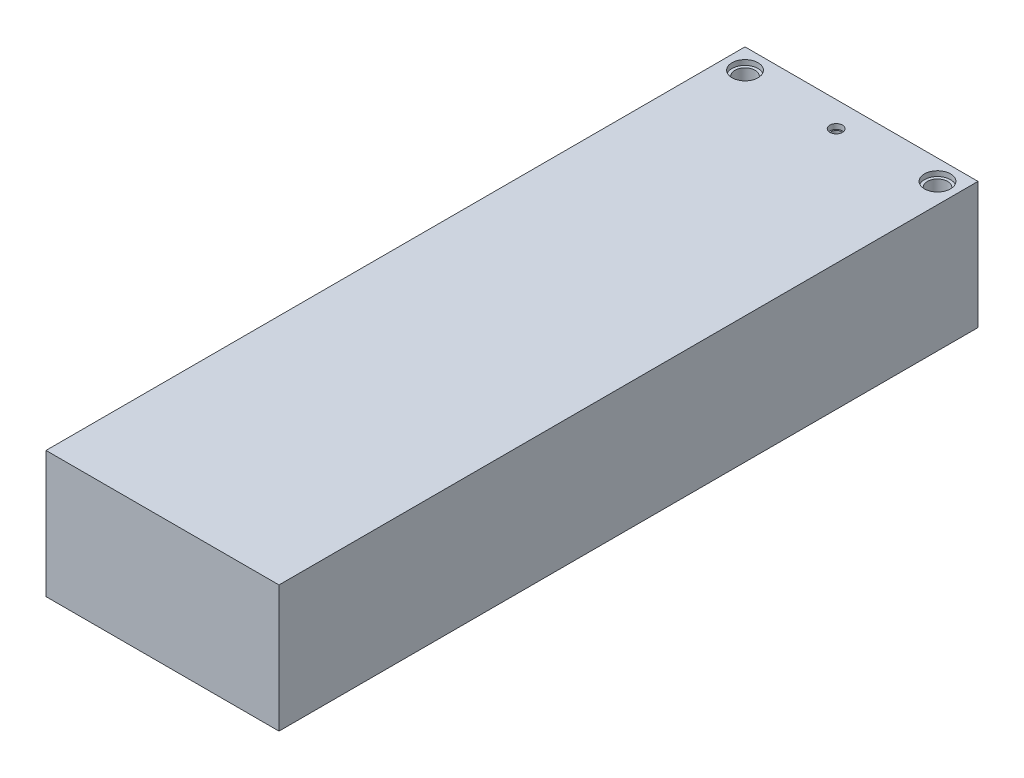
from build123d import *

# Parameters (mm, degrees)
SKETCH2_W           = 46
SKETCH2_H           = 25
BOSS_EXTRUDE1_DEPTH = 138
SKETCH3_R           = 2.575
SKETCH3_R_2         = 1.25
CUT_EXTRUDE1_DEPTH  = 1
SKETCH4_R           = 2
SKETCH4_R_2         = 1
CUT_EXTRUDE2_DEPTH  = 16.5


with BuildPart() as part:
    # Sketch2 → Boss-Extrude1 (new body)
    with BuildSketch(Plane.XY):
        Rectangle(SKETCH2_W, SKETCH2_H)
    extrude(amount=BOSS_EXTRUDE1_DEPTH)

    # Sketch3 → Cut-Extrude1 (cut)
    with BuildSketch(Plane(origin=(0, 12.5, 0), x_dir=(1, 0, 0), z_dir=(0, 1, 0))):
        with Locations((-19, -4)):
            Circle(SKETCH3_R)
        with Locations((0, -5)):
            Circle(SKETCH3_R_2)
        with Locations((19, -4)):
            Circle(SKETCH3_R)
    extrude(amount=-CUT_EXTRUDE1_DEPTH, mode=Mode.SUBTRACT)

    # Sketch4 → Cut-Extrude2 (cut)
    with BuildSketch(Plane(origin=(0, 12.5, 0), x_dir=(1, 0, 0), z_dir=(0, 1, 0))):
        with Locations((-19, -4)):
            Circle(SKETCH4_R)
        with Locations((19, -4)):
            Circle(SKETCH4_R)
        with Locations((0, -5)):
            Circle(SKETCH4_R_2)
    extrude(amount=-CUT_EXTRUDE2_DEPTH, mode=Mode.SUBTRACT)


solid = part.part
